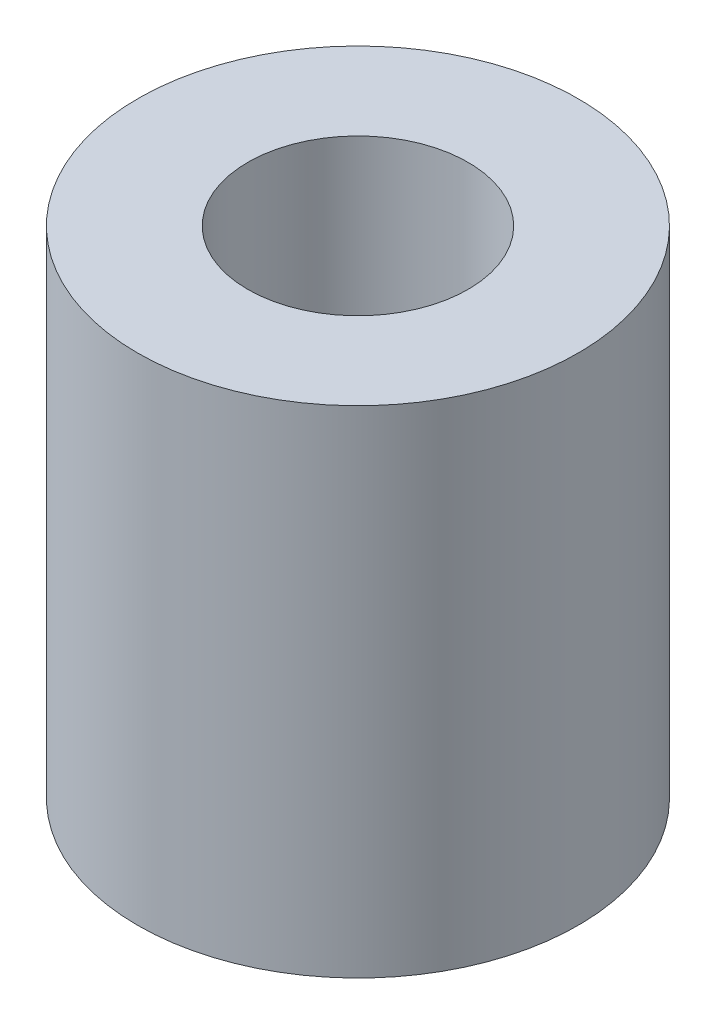
from build123d import *

# Parameters (mm, degrees)
SKETCH_1_R      = 6
SKETCH_1_R_2    = 3
EXTRUDE_1_DEPTH = 13.5


with BuildPart() as part:
    # 스케치1 → 보스-돌출1 (new body)
    with BuildSketch(Plane(origin=(0, 0, 0), x_dir=(1, 0, 0), z_dir=(0, 1, 0))):
        Circle(SKETCH_1_R)
        Circle(SKETCH_1_R_2, mode=Mode.SUBTRACT)
    extrude(amount=EXTRUDE_1_DEPTH)


solid = part.part
